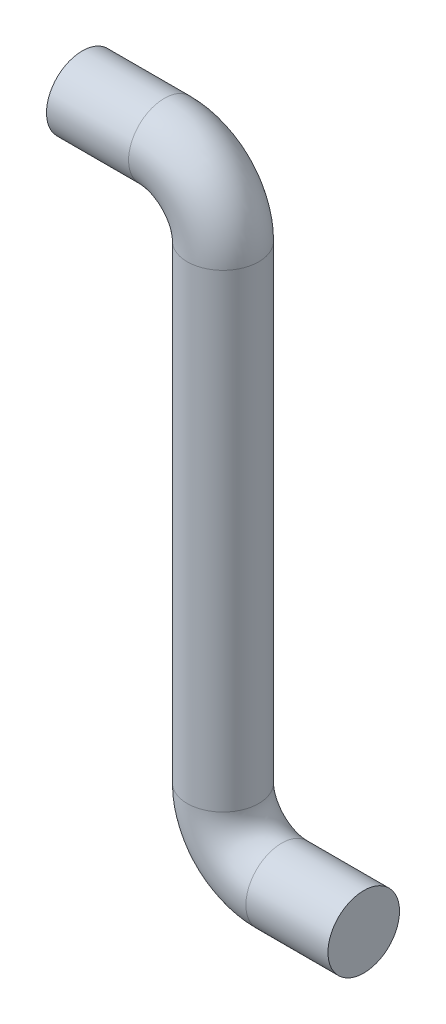
from build123d import *

# Parameters (mm, degrees)
SKETCH2_R = 3.05


with BuildPart() as part:
    # Sweep1: sweep along a path in Sketch1
    with BuildLine(Plane.XY) as sweep1_path:
        Line((0, 0), (-7, 0))
        ThreePointArc((-7, 0), (-10.535533906, 1.464466094), (-12, 5))
        Line((-12, 5), (-12, 45))
        ThreePointArc((-12, 45), (-13.464466094, 48.535533906), (-17, 50))
        Line((-17, 50), (-24, 50))
    # Sketch2 → Sweep1 (sweep)
    with BuildSketch(Plane(origin=(0, 0, 0), x_dir=(0, 0, -1), z_dir=(1, 0, 0))):
        Circle(SKETCH2_R)
    sweep(path=sweep1_path.line)


solid = part.part
